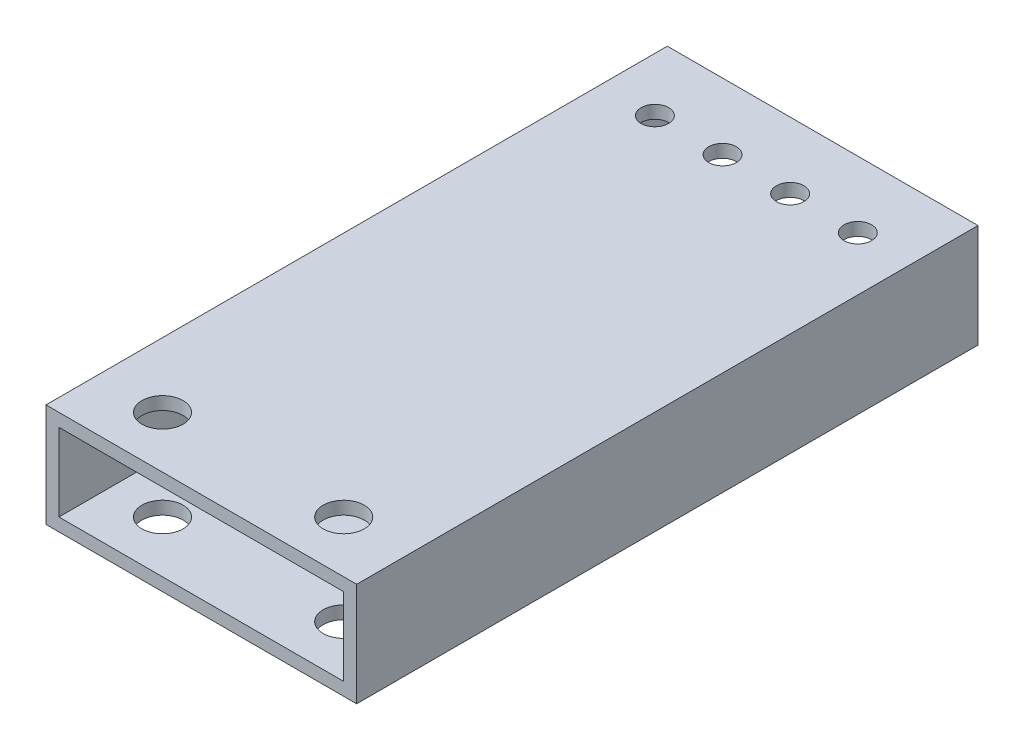
from build123d import *

# Parameters (mm, degrees)
SKETCH1_W           = 76.2
SKETCH1_H           = 25.4
SKETCH1_W_2         = 69.85
SKETCH1_H_2         = 19.05
BOSS_EXTRUDE1_DEPTH = 152.4
SKETCH2_R           = 3.3782
CUT_EXTRUDE1_DEPTH  = 26.4
SKETCH3_R           = 5.0419
CUT_EXTRUDE2_DEPTH  = 26.4


with BuildPart() as part:
    # Sketch1 → Boss-Extrude1 (new body)
    with BuildSketch(Plane.XY):
        with Locations((38.1, 12.7)):
            Rectangle(SKETCH1_W, SKETCH1_H)
        with Locations((38.1, 12.7)):
            Rectangle(SKETCH1_W_2, SKETCH1_H_2, mode=Mode.SUBTRACT)
    extrude(amount=BOSS_EXTRUDE1_DEPTH)

    # Sketch2 → Cut-Extrude1 (cut, through all)
    with BuildSketch(Plane(origin=(0, 25.4, 0), x_dir=(1, 0, 0), z_dir=(0, 1, 0))):
        with Locations((13.21308, -16.2687)):
            Circle(SKETCH2_R)
        with Locations((29.80436, -16.2687)):
            Circle(SKETCH2_R)
        with Locations((46.39564, -16.2687)):
            Circle(SKETCH2_R)
        with Locations((62.98692, -16.2687)):
            Circle(SKETCH2_R)
    extrude(amount=-CUT_EXTRUDE1_DEPTH, mode=Mode.SUBTRACT)

    # Sketch3 → Cut-Extrude2 (cut, through all)
    with BuildSketch(Plane.XZ):
        with Locations((60.325, 139.7)):
            Circle(SKETCH3_R)
        with Locations((15.875, 139.7)):
            Circle(SKETCH3_R)
    extrude(amount=-CUT_EXTRUDE2_DEPTH, mode=Mode.SUBTRACT)


solid = part.part
